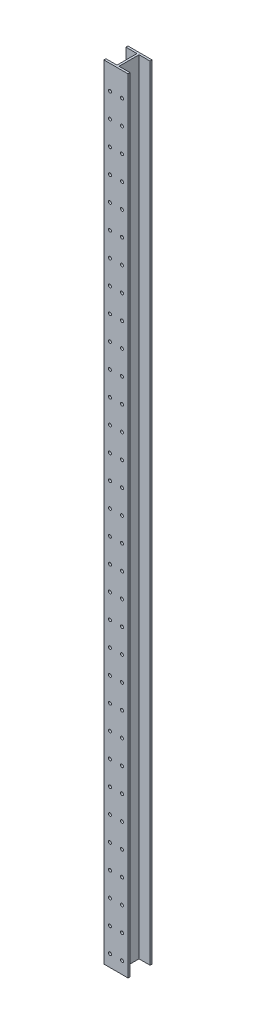
from build123d import *

# Parameters (mm, degrees)
BOSS_EXTRUDE1_DEPTH = 3302
SKETCH2_R           = 6.35
CUT_EXTRUDE1_DEPTH  = 8.636
LPATTERN1_COUNT     = 32
LPATTERN1_PITCH     = 101.6


with BuildPart() as part:
    # Sketch1 → Boss-Extrude1 (new body)
    with BuildSketch(Plane(origin=(0, 0, 0), x_dir=(1, 0, 0), z_dir=(0, 1, 0))):
        Polygon((-4.318, -42.164), (-4.318, 42.164), (-50.8, 42.164), (-50.8, 50.8), (50.8, 50.8), (50.8, 42.164), (4.318, 42.164), (4.318, -42.164), (50.8, -42.164), (50.8, -50.8), (-50.8, -50.8), (-50.8, -42.164), align=None)
    extrude(amount=BOSS_EXTRUDE1_DEPTH)

    # Sketch2 → Cut-Extrude1 (cut)
    with BuildSketch(Plane.XY.offset(50.8)):
        with Locations((-25.4, 50.8)):
            Circle(SKETCH2_R)
        with Locations((25.4, 50.8)):
            Circle(SKETCH2_R)
    cut_extrude1 = extrude(amount=-CUT_EXTRUDE1_DEPTH, mode=Mode.SUBTRACT)

    # LPattern1: Cut-Extrude1 ×32
    with Locations(*[(0, i * LPATTERN1_PITCH, 0) for i in range(1, LPATTERN1_COUNT)]):
        add(cut_extrude1, mode=Mode.SUBTRACT)


solid = part.part
